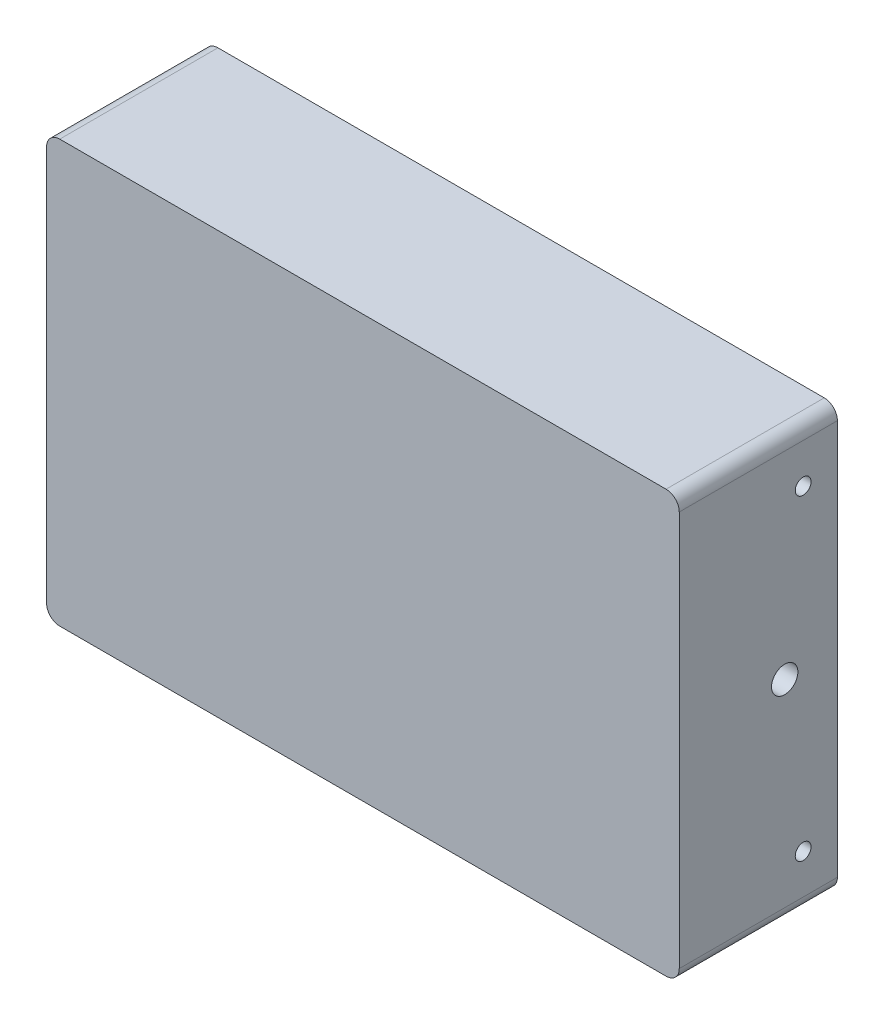
from build123d import *

# Parameters (mm, degrees)
SKETCH2_W               = 75
SKETCH2_H               = 45
BOSS_EXTRUDE1_DEPTH     = 20
SKETCH3_W               = 110
SKETCH3_H               = 80
BOSS_EXTRUDE2_DEPTH     = 10
SKETCH4_W               = 1.25
SKETCH4_H               = 2.8
CUT_EXTRUDE1_DEPTH      = 10
SKETCH5_W               = 30
SKETCH5_H               = 80
BOSS_EXTRUDE4_DEPTH     = 10
SKETCH8_R               = 1.5
CUT_EXTRUDE2_DEPTH      = 120
SKETCH9_R               = 2.5
CUT_EXTRUDE3_DEPTH      = 40
CUT_EXTRUDE3_DEPTH_BACK = 20
SKETCH10_W              = 3.7
SKETCH10_H              = 8
CUT_EXTRUDE4_DEPTH      = 15
FILLET1_R               = 2.5


with BuildPart() as part:
    # Sketch2 → Boss-Extrude1 (new body)
    with BuildSketch(Plane.XY):
        Polygon((42.5, -22.5), (42.5, 22.5), (55, 22.5), (55, 40), (-55, 40), (-55, -40), (55, -40), (55, -22.5), align=None)
        with BuildLine():
            Line((-37.5, -22.5), (-37.5, 22.5))
            Line((-37.5, 22.5), (-37.5, 26))
            ThreePointArc((-37.5, 26), (-40.328427125, 32.828427125), (-33.5, 30))
            Line((-33.5, 30), (33.5, 30))
            ThreePointArc((33.5, 30), (37.5, 34), (41.5, 30))
            ThreePointArc((41.5, 30), (40.328427125, 27.171572875), (37.5, 26))
            Line((37.5, 26), (37.5, 22.5))
            Line((37.5, 22.5), (37.5, -22.5))
            Line((37.5, -22.5), (37.5, -26))
            ThreePointArc((37.5, -26), (40.328427125, -27.171572875), (41.5, -30))
            ThreePointArc((41.5, -30), (37.5, -34), (33.5, -30))
            Line((33.5, -30), (-33.5, -30))
            ThreePointArc((-33.5, -30), (-40.328427125, -32.828427125), (-37.5, -26))
            Line((-37.5, -26), (-37.5, -22.5))
        make_face(mode=Mode.SUBTRACT)
        with BuildLine():
            Line((-37.5, 26), (-37.5, 22.5))
            Line((-37.5, 22.5), (37.5, 22.5))
            Line((37.5, 22.5), (37.5, 26))
            ThreePointArc((37.5, 26), (34.671572875, 27.171572875), (33.5, 30))
            Line((33.5, 30), (-33.5, 30))
            ThreePointArc((-33.5, 30), (-34.671572875, 27.171572875), (-37.5, 26))
        make_face()
        Rectangle(SKETCH2_W, SKETCH2_H)
        with BuildLine():
            Line((37.5, -22.5), (-37.5, -22.5))
            Line((-37.5, -22.5), (-37.5, -26))
            ThreePointArc((-37.5, -26), (-34.671572875, -27.171572875), (-33.5, -30))
            Line((-33.5, -30), (33.5, -30))
            ThreePointArc((33.5, -30), (34.671572875, -27.171572875), (37.5, -26))
            Line((37.5, -26), (37.5, -22.5))
        make_face()
    extrude(amount=BOSS_EXTRUDE1_DEPTH)

    # Sketch3 → Boss-Extrude2 (add)
    with BuildSketch(Plane.XY.offset(20)):
        Rectangle(SKETCH3_W, SKETCH3_H)
    extrude(amount=BOSS_EXTRUDE2_DEPTH)

    # Sketch4 → Cut-Extrude1 (cut)
    with BuildSketch(Plane.XY):
        Polygon((43.75, 32.8), (43.75, 30), (45, 30), (45, 27.2), (46.25, 27.2), (46.25, 32.8), align=None)
        with Locations((44.375, 28.6)):
            Rectangle(SKETCH4_W, SKETCH4_H)
        Polygon((-45, 27.2), (-45, 30), (-43.75, 30), (-43.75, 32.8), (-46.25, 32.8), (-46.25, 27.2), align=None)
        with Locations((-44.375, 28.6)):
            Rectangle(SKETCH4_W, SKETCH4_H)
        with Locations((-44.375, -28.6)):
            Rectangle(SKETCH4_W, SKETCH4_H)
        Polygon((-45, -30), (-45, -27.2), (-46.25, -27.2), (-46.25, -32.8), (-43.75, -32.8), (-43.75, -30), align=None)
        Polygon((46.25, -27.2), (45, -27.2), (45, -30), (43.75, -30), (43.75, -32.8), (46.25, -32.8), align=None)
        with Locations((44.375, -28.6)):
            Rectangle(SKETCH4_W, SKETCH4_H)
    extrude(amount=CUT_EXTRUDE1_DEPTH, mode=Mode.SUBTRACT)

    # Sketch5 → Boss-Extrude4 (add)
    with BuildSketch(Plane(origin=(55, 0, 0), x_dir=(0, 0, -1), z_dir=(1, 0, 0))):
        with Locations((-15, 0)):
            Rectangle(SKETCH5_W, SKETCH5_H)
    extrude(amount=BOSS_EXTRUDE4_DEPTH)

    # Sketch8 → Cut-Extrude2 (cut)
    with BuildSketch(Plane(origin=(65, 0, 0), x_dir=(0, 0, -1), z_dir=(1, 0, 0))):
        with Locations((-6.5, 30)):
            Circle(SKETCH8_R)
        with Locations((-6.5, -30)):
            Circle(SKETCH8_R)
    extrude(amount=-CUT_EXTRUDE2_DEPTH, mode=Mode.SUBTRACT)

    # Sketch9 → Cut-Extrude3 (cut, two sides)
    with BuildSketch(Plane(origin=(42.5, 0, 0), x_dir=(0, 0, -1), z_dir=(1, 0, 0))) as cut_extrude3_sk:
        with Locations((-10, 0)):
            Circle(SKETCH9_R)
    extrude(amount=CUT_EXTRUDE3_DEPTH, mode=Mode.SUBTRACT)
    extrude(cut_extrude3_sk.sketch, amount=-CUT_EXTRUDE3_DEPTH_BACK, mode=Mode.SUBTRACT)

    # Sketch10 → Cut-Extrude4 (cut)
    with BuildSketch(Plane(origin=(0, 0, 0), x_dir=(-1, 0, 0), z_dir=(0, 0, -1))):
        with Locations((-35.65, 0)):
            Rectangle(SKETCH10_W, SKETCH10_H)
        with Locations((-59.35, 0)):
            Rectangle(SKETCH10_W, SKETCH10_H)
    extrude(amount=-CUT_EXTRUDE4_DEPTH, mode=Mode.SUBTRACT)

    # Fillet1
    fillet1_edges = [part.edges().sort_by_distance(p)[0] for p in [
        (65, -40, 15),
        (65, 40, 15),
        (-55, -40, 15),
        (-55, 40, 15),
    ]]
    fillet(fillet1_edges, radius=FILLET1_R)


solid = part.part
